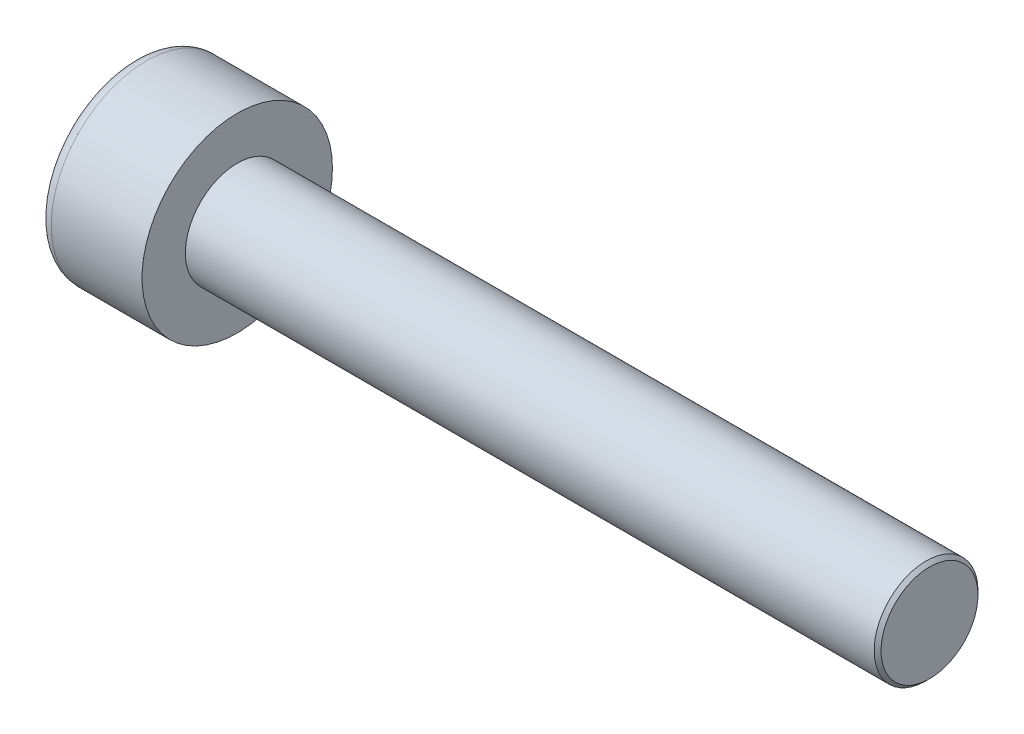
from build123d import *

# Parameters (mm, degrees)
SKETCH1_R           = 2.75
BASEHEAD_DEPTH      = 3
SKETCH2_R           = 1.5
BASEBODY_DEPTH      = 20
HEXAGONSOCKET_DEPTH = 1.3
TOPFILLET_R         = 0.375
CHAMFER1_SIZE       = 0.1


with BuildPart() as part:
    # Sketch1 → BaseHead (new body)
    with BuildSketch(Plane(origin=(0, 0, 0), x_dir=(0, 0, -1), z_dir=(1, 0, 0))):
        Circle(SKETCH1_R)
    extrude(amount=BASEHEAD_DEPTH)

    # Sketch2 → BaseBody (add)
    with BuildSketch(Plane(origin=(3, 0, 0), x_dir=(0, 0, -1), z_dir=(1, 0, 0))):
        Circle(SKETCH2_R)
    extrude(amount=BASEBODY_DEPTH)

    # Sketch3 → HexagonSocket (cut)
    with BuildSketch(Plane(origin=(0, 0, 0), x_dir=(0, 0, -1), z_dir=(1, 0, 0))):
        Polygon((1.443375673, 0), (0.721687836, 1.25), (-0.721687836, 1.25), (-1.443375673, 0), (-0.721687836, -1.25), (0.721687836, -1.25), align=None)
    extrude(amount=HEXAGONSOCKET_DEPTH, mode=Mode.SUBTRACT)

    # Sketch4 → Cut-Revolve1 (revolve, cut)
    with BuildSketch(Plane(origin=(-4.19613823, 0.75, 0), x_dir=(-1, 0, 0), z_dir=(0, 0, 1))):
        Polygon((-5.49613823, 2), (-6.217826066, 0.75), (-5.49613823, 0.75), align=None)
    revolve(axis=Axis((0.838992387, 0, 0), (-1, 0, 0)), mode=Mode.SUBTRACT)

    # TopFillet
    topfillet_edges = [part.edges().sort_by_distance(p)[0] for p in [
        (0, 0, 2.75),
    ]]
    fillet(topfillet_edges, radius=TOPFILLET_R)

    # Chamfer1
    chamfer1_edges = [part.edges().sort_by_distance(p)[0] for p in [
        (23, 0, 1.5),
    ]]
    chamfer(chamfer1_edges, length=CHAMFER1_SIZE)


solid = part.part
